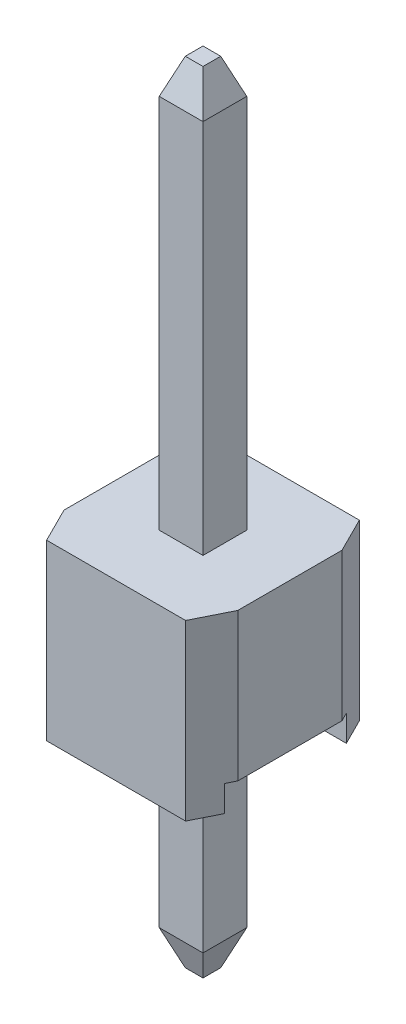
from build123d import *

# Parameters (mm, degrees)
SKETCH1_W             = 2.54
SKETCH1_H             = 2.54
MAIN_BODY_DEPTH       = 2.54
SKETCH3_W             = 1.778
SKETCH3_H             = 0.381
CUT_EXTRUDE1_DEPTH    = 3.54
CUT_EXTRUDE2_DEPTH    = 3.54
SKETCH2_W             = 0.64
SKETCH2_H             = 0.64
PIN_DEPTH             = 6
PIN_DEPTH_BACK        = 5.54
CHAMFER1_SIZE         = 0.508
CHAMFER1_SIZE2        = 0.1905
CHAMFER1_PART_2_SIZE  = 0.508
CHAMFER1_PART_2_SIZE2 = 0.1905
CHAMFER1_PART_3_SIZE  = 0.508
CHAMFER1_PART_3_SIZE2 = 0.1905
CHAMFER1_PART_4_SIZE  = 0.508
CHAMFER1_PART_4_SIZE2 = 0.1905
CHAMFER2_SIZE         = 0.1905
CHAMFER2_SIZE2        = 0.508


with BuildPart() as part:
    # Sketch1 → Main Body (new body)
    with BuildSketch(Plane(origin=(0, 0, 0), x_dir=(1, 0, 0), z_dir=(0, 1, 0))):
        with Locations((1.27, 1.27)):
            Rectangle(SKETCH1_W, SKETCH1_H)
    extrude(amount=MAIN_BODY_DEPTH)

    # Sketch3 → Cut-Extrude1 (cut, through all)
    with BuildSketch(Plane.ZY):
        with Locations((-1.27, 0.1905)):
            Rectangle(SKETCH3_W, SKETCH3_H)
    extrude(amount=-CUT_EXTRUDE1_DEPTH, mode=Mode.SUBTRACT)

    # Sketch4 → Cut-Extrude2 (cut, through all)
    with BuildSketch(Plane(origin=(0, 2.54, 0), x_dir=(1, 0, 0), z_dir=(0, 1, 0))):
        Polygon((0.254, 2.54), (0, 2.54), (0, 2.032), align=None)
        Polygon((2.54, 2.54), (2.286, 2.54), (2.54, 2.032), align=None)
        Polygon((0.254, 0), (0, 0.508), (0, 0), align=None)
        Polygon((2.54, 0), (2.286, 0), (2.54, 0.508), align=None)
    extrude(amount=-CUT_EXTRUDE2_DEPTH, mode=Mode.SUBTRACT)

    # Sketch2 → Pin (add, two sides)
    with BuildSketch(Plane(origin=(0, 2.54, 0), x_dir=(1, 0, 0), z_dir=(0, 1, 0))) as pin_sk:
        with Locations((1.27, 1.27)):
            Rectangle(SKETCH2_W, SKETCH2_H)
    extrude(amount=PIN_DEPTH)
    extrude(pin_sk.sketch, amount=-PIN_DEPTH_BACK)

    # Chamfer1
    chamfer1_edges = [part.edges().sort_by_distance(p)[0] for p in [
        (0.95, 8.54, -1.27),
    ]]
    chamfer1_side = [part.faces().sort_by_distance(p)[0] for p in [
        (0.95, 5.54, -1.27),
    ]]
    chamfer(chamfer1_edges, length=CHAMFER1_SIZE, length2=CHAMFER1_SIZE2, reference=chamfer1_side[0])

    # Chamfer1 part 2
    chamfer1_part_2_edges = [part.edges().sort_by_distance(p)[0] for p in [
        (1.27, 8.54, -0.95),
    ]]
    chamfer1_part_2_side = [part.faces().sort_by_distance(p)[0] for p in [
        (1.27, 5.54, -0.95),
    ]]
    chamfer(chamfer1_part_2_edges, length=CHAMFER1_PART_2_SIZE, length2=CHAMFER1_PART_2_SIZE2, reference=chamfer1_part_2_side[0])

    # Chamfer1 part 3
    chamfer1_part_3_edges = [part.edges().sort_by_distance(p)[0] for p in [
        (1.59, 8.54, -1.27),
    ]]
    chamfer1_part_3_side = [part.faces().sort_by_distance(p)[0] for p in [
        (1.59, 5.54, -1.27),
    ]]
    chamfer(chamfer1_part_3_edges, length=CHAMFER1_PART_3_SIZE, length2=CHAMFER1_PART_3_SIZE2, reference=chamfer1_part_3_side[0])

    # Chamfer1 part 4
    chamfer1_part_4_edges = [part.edges().sort_by_distance(p)[0] for p in [
        (1.27, 8.54, -1.59),
    ]]
    chamfer1_part_4_side = [part.faces().sort_by_distance(p)[0] for p in [
        (1.27, 5.54, -1.59),
    ]]
    chamfer(chamfer1_part_4_edges, length=CHAMFER1_PART_4_SIZE, length2=CHAMFER1_PART_4_SIZE2, reference=chamfer1_part_4_side[0])

    # Chamfer2
    chamfer2_edges = [part.edges().sort_by_distance(p)[0] for p in [
        (1.27, -3, -1.59),
        (0.95, -3, -1.27),
        (1.27, -3, -0.95),
        (1.59, -3, -1.27),
    ]]
    chamfer2_side = [part.faces().sort_by_distance(p)[0] for p in [
        (1.27, -3, -1.27),
    ]]
    chamfer(chamfer2_edges, length=CHAMFER2_SIZE, length2=CHAMFER2_SIZE2, reference=chamfer2_side[0])


solid = part.part
